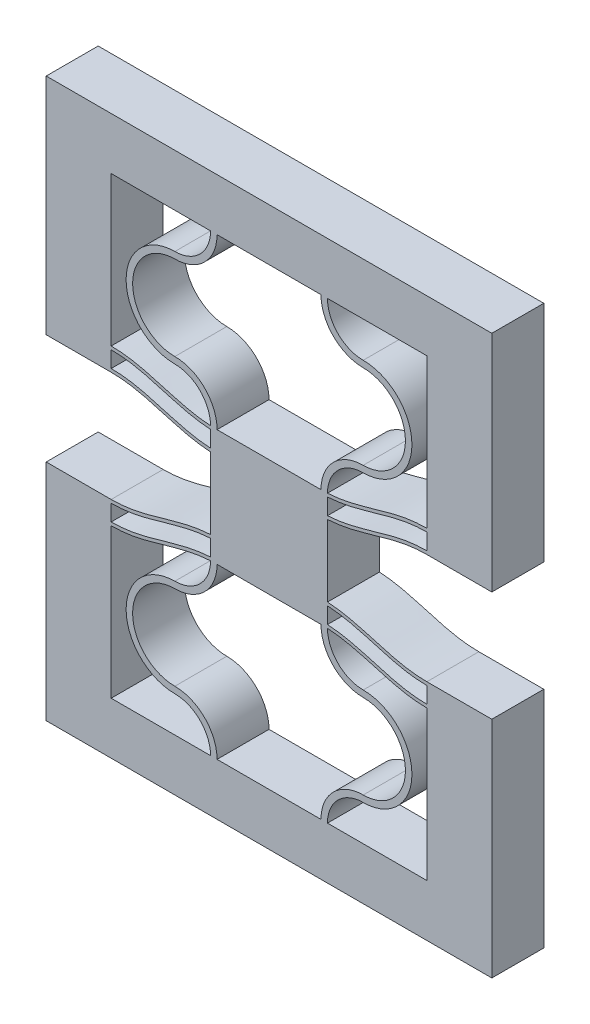
from build123d import *

# Parameters (mm, degrees)
BOSS_EXTRUDE1_DEPTH = 4
SKETCH4_W           = 1.000070162
SKETCH4_H           = 4
BOSS_EXTRUDE2_DEPTH = 1.5
SKETCH7_W           = 4
SKETCH7_H           = 4
SKETCH7_H_2         = 8.978724008
BOSS_EXTRUDE3_DEPTH = 4


with BuildPart() as part:
    # Sketch1 → Boss-Extrude1 (new body)
    with BuildSketch(Plane.XY):
        with BuildLine():
            add(Edge.make_bspline(
                [(8.650034128, 14.736109631), (8.680746517, 14.734408619), (8.867008974, 14.723257965), (9.208262215, 14.693590447), (9.806171852, 14.6130028), (10.672825359, 14.435515205), (11.526338992, 14.20479694), (12.374355272, 13.955307056), (13.036468999, 13.76722335), (13.463983625, 13.65379595), (13.867714729, 13.554584941), (14.199458725, 13.480664012), (14.541813741, 13.412949376), (14.904541585, 13.354312716), (15.169364817, 13.318181333), (15.410962579, 13.293235216), (15.590043186, 13.276641786), (15.773063806, 13.26594608), (15.91347791, 13.255862601), (16.140650664, 13.251352295), (16.234904832, 13.249999196), (16.299999999, 13.249999196)],
                knots=[0.525125302, 0.525125302, 0.525125302, 0.525125302, 0.525125302, 0.531304341, 0.56260868, 0.593913043, 0.646253955, 0.708862692, 0.740167057, 0.771471422, 0.784556649, 0.797641876, 0.823812331, 0.839464521, 0.855116711, 0.870768874, 0.878594956, 0.886421037, 0.894247124, 0.902073211, 0.917725385, 0.917725385, 0.917725385, 0.917725385, 0.917725385], degree=4))
            Line((8.650034128, 14.736109631), (8.650034128, 15.989362004))
            Line((8.650034128, 15.989362004), (7.649963966, 15.989362004))
            Line((7.649963966, 15.989362004), (7.649963966, 14.736109631))
            add(Edge.make_bspline(
                [(-1e-09, 13.249999196), (0.065095167, 13.249999196), (0.160181304, 13.251352278), (0.379506189, 13.255862627), (0.568214789, 13.267962739), (0.827693171, 13.285320966), (1.082221836, 13.313020221), (1.400554209, 13.354312115), (1.754866072, 13.412950352), (2.166779115, 13.493219693), (2.64640513, 13.604197637), (3.201137077, 13.749429205), (3.925467767, 13.955306407), (4.773787171, 14.204797394), (5.627102569, 14.43551494), (6.493859639, 14.613002926), (7.091730736, 14.693590402), (7.4329861, 14.723257951), (7.619251146, 14.734408618), (7.649963966, 14.736109631)],
                knots=[0.082274615, 0.082274615, 0.082274615, 0.082274615, 0.082274615, 0.097926789, 0.105752876, 0.113578963, 0.129231126, 0.144883289, 0.160535479, 0.176187669, 0.202358124, 0.228528578, 0.259832943, 0.291137308, 0.353746045, 0.406086957, 0.43739132, 0.468695659, 0.474874695, 0.474874695, 0.474874695, 0.474874695, 0.474874695], degree=4))
            Line((0, 13.249999196), (-4.999916786, 13.249999196))
            Line((-4.999916786, 13.249999196), (-4.999916786, -4))
            Line((-4.999916786, -4), (21.299916786, -4))
            Line((21.299916786, -4), (21.299916786, 13.249999196))
            Line((21.299916786, 13.249999196), (16.3, 13.249999196))
        make_face()
        with BuildLine():
            Line((7.649963966, 14.486109631), (7.649963966, 13.236109631))
            add(Edge.make_bspline(
                [(-1e-09, 11.749999196), (0.065095167, 11.749999196), (0.160181304, 11.751352278), (0.379506188, 11.755862627), (0.568214789, 11.767962739), (0.827693171, 11.785320966), (1.082221836, 11.813020221), (1.400554209, 11.854312115), (1.754866072, 11.912950352), (2.166779114, 11.993219693), (2.64640513, 12.104197637), (3.201137076, 12.249429205), (3.925467766, 12.455306407), (4.773787171, 12.704797394), (5.627102569, 12.93551494), (6.493859639, 13.113002926), (7.091730736, 13.193590402), (7.4329861, 13.223257951), (7.619251146, 13.234408618), (7.649963966, 13.236109631)],
                knots=[0.082274615, 0.082274615, 0.082274615, 0.082274615, 0.082274615, 0.097926789, 0.105752876, 0.113578963, 0.129231126, 0.144883289, 0.160535479, 0.176187669, 0.202358124, 0.228528578, 0.259832943, 0.291137308, 0.353746045, 0.406086957, 0.43739132, 0.468695659, 0.474874695, 0.474874695, 0.474874695, 0.474874695, 0.474874695], degree=4))
            Line((0, 11.749999196), (0, 12.999999196))
            add(Edge.make_bspline(
                [(-1e-09, 12.999999196), (0.065095167, 12.999999196), (0.160181304, 13.001352278), (0.379506189, 13.005862627), (0.568214789, 13.017962739), (0.827693171, 13.035320966), (1.082221836, 13.063020221), (1.400554209, 13.104312115), (1.754866072, 13.162950352), (2.166779114, 13.243219693), (2.64640513, 13.354197637), (3.201137076, 13.499429205), (3.925467767, 13.705306407), (4.773787171, 13.954797394), (5.627102569, 14.18551494), (6.493859639, 14.363002926), (7.091730736, 14.443590402), (7.4329861, 14.473257951), (7.619251146, 14.484408618), (7.649963966, 14.486109631)],
                knots=[0.082274615, 0.082274615, 0.082274615, 0.082274615, 0.082274615, 0.097926789, 0.105752876, 0.113578963, 0.129231126, 0.144883289, 0.160535479, 0.176187669, 0.202358124, 0.228528578, 0.259832943, 0.291137308, 0.353746045, 0.406086957, 0.43739132, 0.468695659, 0.474874695, 0.474874695, 0.474874695, 0.474874695, 0.474874695], degree=4))
        make_face(mode=Mode.SUBTRACT)
        with BuildLine():
            Line((8.650034128, 13.236109631), (8.650034128, 14.486109631))
            add(Edge.make_bspline(
                [(8.650034128, 14.486109631), (8.680746517, 14.484408619), (8.867008974, 14.473257965), (9.208262215, 14.443590447), (9.806171852, 14.3630028), (10.672825359, 14.185515205), (11.526338992, 13.95479694), (12.374355272, 13.705307056), (13.036468999, 13.51722335), (13.463983625, 13.40379595), (13.867714729, 13.304584941), (14.199458725, 13.230664012), (14.541813741, 13.162949376), (14.904541584, 13.104312716), (15.169364817, 13.068181333), (15.410962579, 13.043235216), (15.590043186, 13.026641786), (15.773063806, 13.01594608), (15.91347791, 13.005862601), (16.140650664, 13.001352295), (16.234904832, 12.999999196), (16.299999999, 12.999999196)],
                knots=[0.525125302, 0.525125302, 0.525125302, 0.525125302, 0.525125302, 0.531304341, 0.56260868, 0.593913043, 0.646253955, 0.708862692, 0.740167057, 0.771471422, 0.784556649, 0.797641876, 0.823812331, 0.839464521, 0.855116711, 0.870768874, 0.878594956, 0.886421037, 0.894247124, 0.902073211, 0.917725385, 0.917725385, 0.917725385, 0.917725385, 0.917725385], degree=4))
            Line((16.3, 12.999999196), (16.3, 11.749999196))
            add(Edge.make_bspline(
                [(8.650034128, 13.236109631), (8.680746517, 13.234408619), (8.867008974, 13.223257965), (9.208262215, 13.193590447), (9.806171852, 13.1130028), (10.672825359, 12.935515205), (11.526338992, 12.70479694), (12.374355272, 12.455307056), (13.036468998, 12.26722335), (13.463983625, 12.15379595), (13.867714729, 12.054584941), (14.199458725, 11.980664012), (14.54181374, 11.912949376), (14.904541584, 11.854312716), (15.169364817, 11.818181333), (15.410962578, 11.793235216), (15.590043186, 11.776641786), (15.773063806, 11.76594608), (15.91347791, 11.755862601), (16.140650663, 11.751352295), (16.234904832, 11.749999196), (16.299999999, 11.749999196)],
                knots=[0.525125302, 0.525125302, 0.525125302, 0.525125302, 0.525125302, 0.531304341, 0.56260868, 0.593913043, 0.646253955, 0.708862692, 0.740167057, 0.771471422, 0.784556649, 0.797641876, 0.823812331, 0.839464521, 0.855116711, 0.870768874, 0.878594956, 0.886421037, 0.894247124, 0.902073211, 0.917725385, 0.917725385, 0.917725385, 0.917725385, 0.917725385], degree=4))
        make_face(mode=Mode.SUBTRACT)
        with BuildLine():
            Line((0, 0), (0, 11.499999196))
            add(Edge.make_bspline(
                [(-1e-09, 11.499999196), (0.065095166, 11.499999196), (0.160181304, 11.501352278), (0.379506188, 11.505862627), (0.568214788, 11.517962739), (0.827693171, 11.535320966), (1.082221836, 11.563020221), (1.400554209, 11.604312115), (1.754866071, 11.662950352), (2.166779114, 11.743219693), (2.64640513, 11.854197637), (3.201137076, 11.999429205), (3.925467766, 12.205306407), (4.773787171, 12.454797394), (5.627102568, 12.68551494), (6.493859639, 12.863002926), (7.091730736, 12.943590402), (7.4329861, 12.973257951), (7.619251146, 12.984408618), (7.649963966, 12.986109631)],
                knots=[0.082274615, 0.082274615, 0.082274615, 0.082274615, 0.082274615, 0.097926789, 0.105752876, 0.113578963, 0.129231126, 0.144883289, 0.160535479, 0.176187669, 0.202358124, 0.228528578, 0.259832943, 0.291137308, 0.353746045, 0.406086957, 0.43739132, 0.468695659, 0.474874695, 0.474874695, 0.474874695, 0.474874695, 0.474874695], degree=4))
            ThreePointArc((7.649963966, 12.986109631), (6.839625491, 11.05055155), (4.899999047, 10.25))
            ThreePointArc((4.899999047, 10.25), (1.149999047, 6.5), (4.899999047, 2.75))
            ThreePointArc((4.899999047, 2.75), (6.844542695, 1.944543648), (7.649999047, 0))
            Line((7.649999047, 0), (0, 0))
        make_face(mode=Mode.SUBTRACT)
        with BuildLine():
            ThreePointArc((4.899999047, 9.75), (7.198096086, 10.701902961), (8.149999047, 13))
            ThreePointArc((8.149999047, 13), (9.101902008, 10.701902961), (11.399999047, 9.75))
            ThreePointArc((11.399999047, 9.75), (14.649999047, 6.5), (11.399999047, 3.25))
            ThreePointArc((11.399999047, 3.25), (9.101902008, 2.298097039), (8.149999047, 0))
            ThreePointArc((8.149999047, 0), (7.198096086, 2.298097039), (4.899999047, 3.25))
            ThreePointArc((4.899999047, 3.25), (1.649999047, 6.5), (4.899999047, 9.75))
        make_face(mode=Mode.SUBTRACT)
        with BuildLine():
            ThreePointArc((11.399999047, 10.25), (9.460372603, 11.05055155), (8.650034128, 12.986109631))
            add(Edge.make_bspline(
                [(8.650034128, 12.986109631), (8.680746517, 12.984408619), (8.867008974, 12.973257965), (9.208262215, 12.943590447), (9.806171851, 12.8630028), (10.672825359, 12.685515205), (11.526338991, 12.45479694), (12.374355272, 12.205307056), (13.036468998, 12.01722335), (13.463983625, 11.90379595), (13.867714729, 11.804584941), (14.199458724, 11.730664012), (14.54181374, 11.662949376), (14.904541584, 11.604312716), (15.169364817, 11.568181333), (15.410962578, 11.543235216), (15.590043186, 11.526641786), (15.773063806, 11.51594608), (15.91347791, 11.505862601), (16.140650663, 11.501352295), (16.234904831, 11.499999196), (16.299999999, 11.499999196)],
                knots=[0.525125302, 0.525125302, 0.525125302, 0.525125302, 0.525125302, 0.531304341, 0.56260868, 0.593913043, 0.646253955, 0.708862692, 0.740167057, 0.771471422, 0.784556649, 0.797641876, 0.823812331, 0.839464521, 0.855116711, 0.870768874, 0.878594956, 0.886421037, 0.894247124, 0.902073211, 0.917725385, 0.917725385, 0.917725385, 0.917725385, 0.917725385], degree=4))
            Line((16.3, 11.499999196), (16.3, 0))
            Line((16.3, 0), (8.649999047, 0))
            ThreePointArc((8.649999047, 0), (9.455455399, 1.944543648), (11.399999047, 2.75))
            ThreePointArc((11.399999047, 2.75), (15.149999047, 6.5), (11.399999047, 10.25))
        make_face(mode=Mode.SUBTRACT)
    extrude(amount=BOSS_EXTRUDE1_DEPTH)

    # Sketch4 → Boss-Extrude2 (add)
    with BuildSketch(Plane(origin=(0, 15.989362004, 0), x_dir=(1, 0, 0), z_dir=(0, 1, 0))):
        with Locations((8.149999047, -2)):
            Rectangle(SKETCH4_W, SKETCH4_H)
    extrude(amount=BOSS_EXTRUDE2_DEPTH)

    # Mirror3: part across plane


with BuildPart() as part_1:
    add(part.part)
    add(part.part.mirror(Plane.ZX.offset(17.489362004)))

    # Split2
    split(bisect_by=Plane(origin=(8.149999047, 0, 0), x_dir=(0, -1, 0), z_dir=(-1, 0, 0)), keep=Keep.BOTTOM)

    # Sketch7 → Boss-Extrude3 (add)
    with BuildSketch(Plane.ZY.offset(-8.149999047)):
        with Locations((2, 36.978724008)):
            Rectangle(SKETCH7_W, SKETCH7_H)
        with Locations((2, 17.489362004)):
            Rectangle(SKETCH7_W, SKETCH7_H_2)
        with Locations((2, -2)):
            Rectangle(SKETCH7_W, SKETCH7_H)
    extrude(amount=BOSS_EXTRUDE3_DEPTH)

    # Mirror2: part across plane


with BuildPart() as part_2:
    add(part_1.part)
    add(part_1.part.mirror(Plane.ZY.offset(-4.149999047)))


solid = part_2.part
